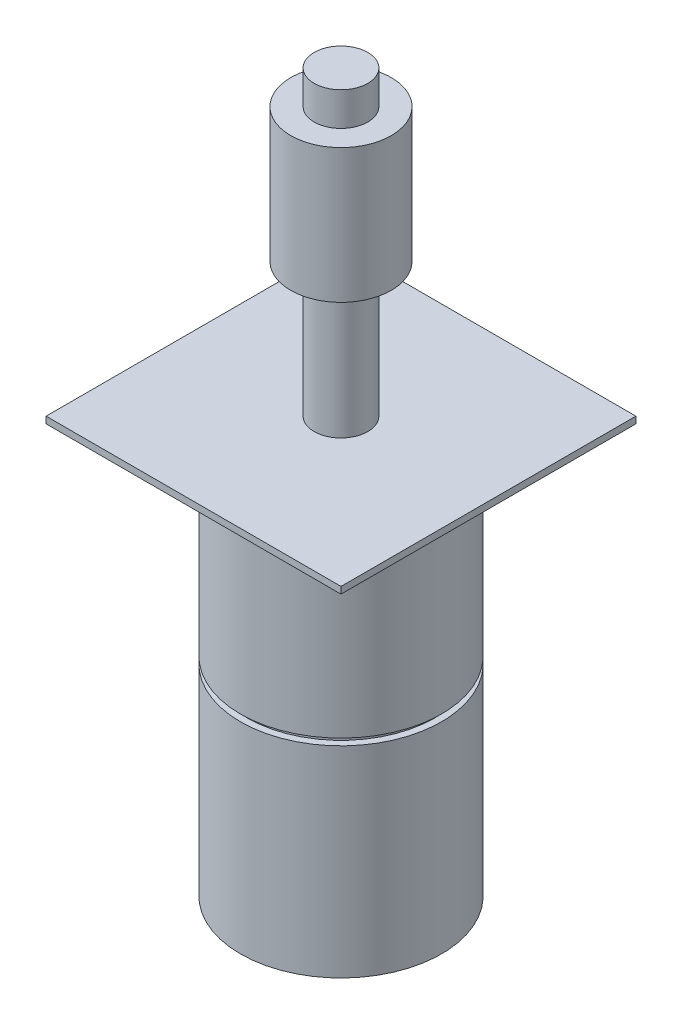
from build123d import *

# Parameters (mm, degrees)
SKETCH1_R           = 15
BOSS_EXTRUDE1_DEPTH = 30
SKETCH2_W           = 44
SKETCH2_H           = 44
BOSS_EXTRUDE2_DEPTH = 1
SKETCH3_R           = 4
BOSS_EXTRUDE3_DEPTH = 20
SKETCH4_R           = 7.5
BOSS_EXTRUDE4_DEPTH = 20
SKETCH5_R           = 4
BOSS_EXTRUDE5_DEPTH = 5
SKETCH6_R           = 14
BOSS_EXTRUDE6_DEPTH = 1
SKETCH7_R           = 15
BOSS_EXTRUDE7_DEPTH = 30
SKETCH8_R           = 4
BOSS_EXTRUDE8_DEPTH = 5


with BuildPart() as part:
    # Sketch1 → Boss-Extrude1 (new body)
    with BuildSketch(Plane(origin=(0, 0, 0), x_dir=(1, 0, 0), z_dir=(0, 1, 0))):
        Circle(SKETCH1_R)
    extrude(amount=BOSS_EXTRUDE1_DEPTH)

    # Sketch2 → Boss-Extrude2 (add)
    with BuildSketch(Plane(origin=(0, 30, 0), x_dir=(1, 0, 0), z_dir=(0, 1, 0))):
        Rectangle(SKETCH2_W, SKETCH2_H)
    extrude(amount=BOSS_EXTRUDE2_DEPTH)

    # Sketch3 → Boss-Extrude3 (add)
    with BuildSketch(Plane(origin=(0, 31, 0), x_dir=(1, 0, 0), z_dir=(0, 1, 0))):
        Circle(SKETCH3_R)
    extrude(amount=BOSS_EXTRUDE3_DEPTH)

    # Sketch4 → Boss-Extrude4 (add)
    with BuildSketch(Plane(origin=(0, 51, 0), x_dir=(1, 0, 0), z_dir=(0, 1, 0))):
        Circle(SKETCH4_R)
    extrude(amount=BOSS_EXTRUDE4_DEPTH)

    # Sketch5 → Boss-Extrude5 (add)
    with BuildSketch(Plane(origin=(0, 71, 0), x_dir=(1, 0, 0), z_dir=(0, 1, 0))):
        Circle(SKETCH5_R)
    extrude(amount=BOSS_EXTRUDE5_DEPTH)

    # Sketch6 → Boss-Extrude6 (add)
    with BuildSketch(Plane(origin=(0, 0, 0), x_dir=(-1, 0, 0), z_dir=(0, -1, 0))):
        Circle(SKETCH6_R)
    extrude(amount=BOSS_EXTRUDE6_DEPTH)

    # Sketch7 → Boss-Extrude7 (add)
    with BuildSketch(Plane(origin=(0, -1, 0), x_dir=(-1, 0, 0), z_dir=(0, -1, 0))):
        Circle(SKETCH7_R)
    extrude(amount=BOSS_EXTRUDE7_DEPTH)

    # Sketch8 → Boss-Extrude8 (add)
    with BuildSketch(Plane(origin=(0, -31, 0), x_dir=(-1, 0, 0), z_dir=(0, -1, 0))):
        Circle(SKETCH8_R)
    extrude(amount=BOSS_EXTRUDE8_DEPTH)


solid = part.part
